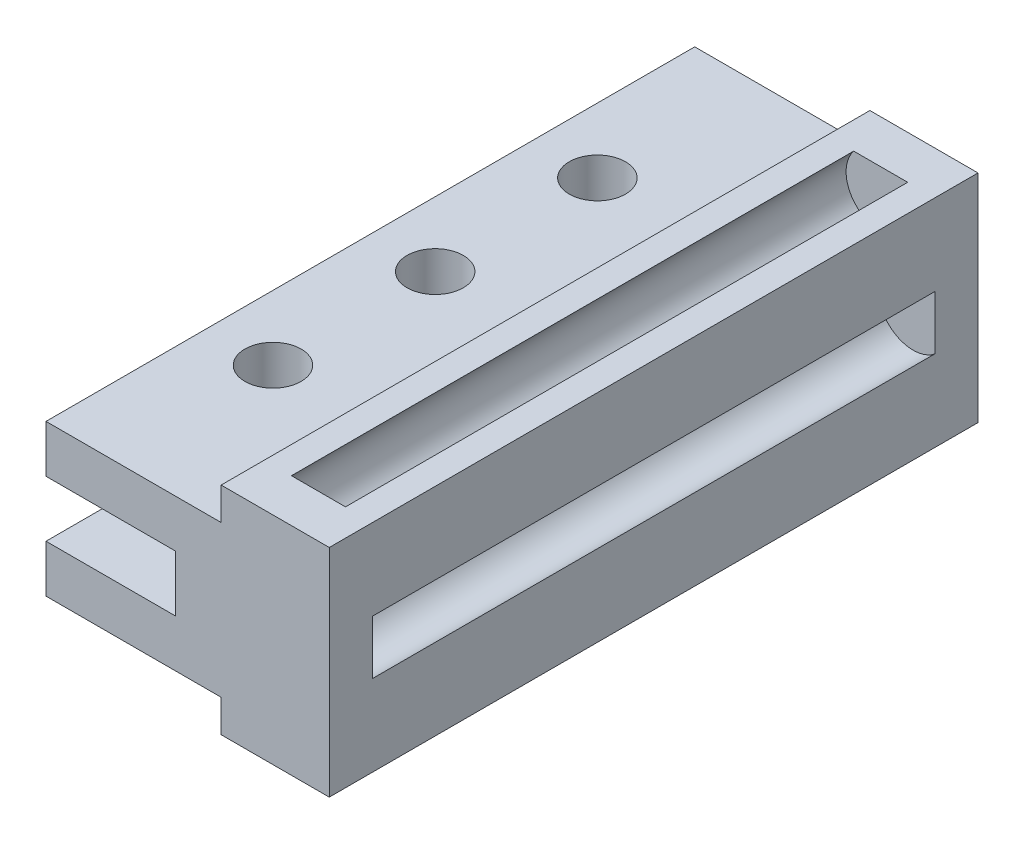
from build123d import *

# Parameters (mm, degrees)
EXTRUDE_1_DEPTH     = 30
SKETCH_2_R          = 1.3
CUT_EXTRUDE_1_DEPTH = 30
SKETCH_3_W          = 5
SKETCH_3_H          = 10
EXTRUDE_2_DEPTH     = 2
EXTRUDE_3_DEPTH     = 2


with BuildPart() as part:
    # 草图1 → 凸台-拉伸1 (new body)
    with BuildSketch(Plane.XY):
        with BuildLine():
            Line((0, 3.5), (-2.1, 3.5))
            Line((-2.1, 3.5), (-8.1, 3.5))
            Line((-8.1, 3.5), (-8.1, 1.3))
            Line((-8.1, 1.3), (-2.1, 1.3))
            Line((-2.1, 1.3), (-2.1, -1.3))
            Line((-2.1, -1.3), (-8.1, -1.3))
            Line((-8.1, -1.3), (-8.1, -3.5))
            Line((-8.1, -3.5), (-2.1, -3.5))
            Line((-2.1, -3.5), (0, -3.5))
            Line((0, -3.5), (0, -5))
            Line((0, -5), (1.2510004, -5))
            ThreePointArc((1.2510004, -5), (2.5, -2.4), (3.7489996, -5))
            Line((3.7489996, -5), (5, -5))
            Line((5, -5), (5, -1.2489996))
            ThreePointArc((5, -1.2489996), (2.4, 0), (5, 1.2489996))
            Line((5, 1.2489996), (5, 5))
            Line((5, 5), (3.7489996, 5))
            ThreePointArc((3.7489996, 5), (2.5, 2.4), (1.2510004, 5))
            Line((1.2510004, 5), (0, 5))
            Line((0, 5), (0, 3.5))
        make_face()
    extrude(amount=EXTRUDE_1_DEPTH)

    # 草图2 → 切除-拉伸1 (cut)
    with BuildSketch(Plane.XZ.offset(3.5)):
        with Locations((-5.099947381, 15.002748372)):
            Circle(SKETCH_2_R)
        with Locations((-5.099947381, 7.501374186)):
            Circle(SKETCH_2_R)
        with Locations((-5.099947381, 22.502748372)):
            Circle(SKETCH_2_R)
    extrude(amount=-CUT_EXTRUDE_1_DEPTH, mode=Mode.SUBTRACT)

    # 草图3 → 凸台-拉伸2 (add)
    with BuildSketch(Plane.XY.offset(30)):
        with Locations((2.5, 0)):
            Rectangle(SKETCH_3_W, SKETCH_3_H)
    extrude(amount=-EXTRUDE_2_DEPTH)

    # 草图4 → 凸台-拉伸3 (add)
    with BuildSketch(Plane(origin=(0, 0, 0), x_dir=(-1, 0, 0), z_dir=(0, 0, -1))):
        with BuildLine():
            Line((0, 3.5), (0, 5))
            Line((0, 5), (-1.2510004, 5))
            ThreePointArc((-1.2510004, 5), (-2.5, 2.4), (-3.7489996, 5))
            Line((-3.7489996, 5), (-5, 5))
            Line((-5, 5), (-5, 1.2489996))
            ThreePointArc((-5, 1.2489996), (-2.4, 0), (-5, -1.2489996))
            Line((-5, -1.2489996), (-5, -5))
            Line((-5, -5), (-3.7489996, -5))
            ThreePointArc((-3.7489996, -5), (-2.5, -2.4), (-1.2510004, -5))
            Line((-1.2510004, -5), (0, -5))
            Line((0, -5), (0, -3.5))
            Line((0, -3.5), (0, 3.5))
        make_face()
        with BuildLine():
            Line((-1.2510004, 5), (-3.7489996, 5))
            ThreePointArc((-3.7489996, 5), (-2.5, 2.4), (-1.2510004, 5))
        make_face()
        with BuildLine():
            ThreePointArc((-5, -1.2489996), (-2.4, 0), (-5, 1.2489996))
            Line((-5, 1.2489996), (-5, -1.2489996))
        make_face()
        with BuildLine():
            Line((-3.7489996, -5), (-1.2510004, -5))
            ThreePointArc((-1.2510004, -5), (-2.5, -2.4), (-3.7489996, -5))
        make_face()
    extrude(amount=-EXTRUDE_3_DEPTH)


solid = part.part
